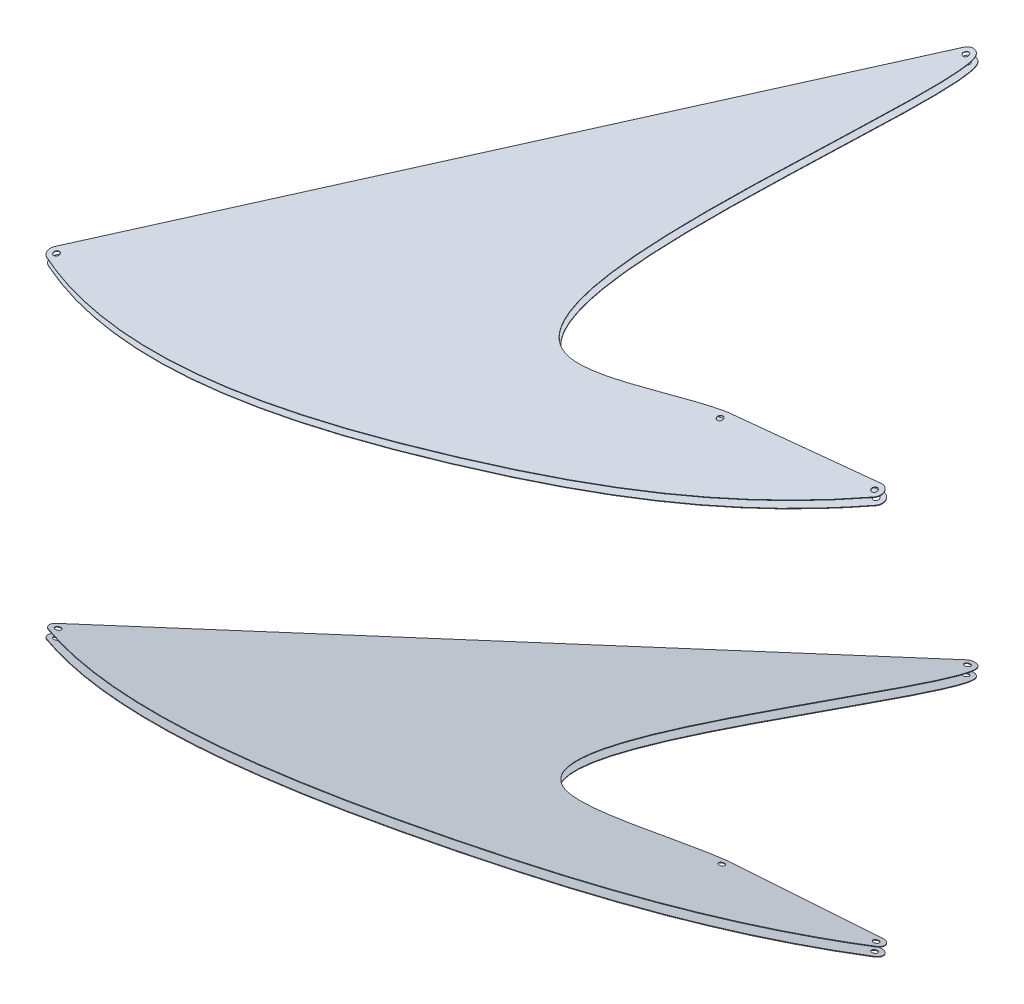
from build123d import *

# Parameters (mm, degrees)
SZKIC1_R                    = 3
SZKIC1_R_2                  = 2.999999996
DODANIE_WYCI_GNI_CIE1_DEPTH = 0.6
SZKIC2_R                    = 3
SZKIC2_R_2                  = 2.999999996
DODANIE_WYCI_GNI_CIE2_DEPTH = 0.6


with BuildPart() as part:
    # Szkic1 → Dodanie-wyciągnięcie1 (new body)
    with BuildSketch(Plane(origin=(0, -365.945689178, 71.13263619), x_dir=(1, 0, 0), z_dir=(0, -0.981627183, 0.190808995))):
        with BuildLine():
            Line((1483.1737317, 808.853368538), (1634.871598877, 794.959745005))
            ThreePointArc((1634.871598877, 794.959745005), (1642.326429132, 800.05707281), (1640.281331001, 808.853368538))
            add(Edge.make_bspline(
                [(1640.281331001, 808.853368538), (1556.499884294, 885.756004267), (1335.806413784, 985.712102893), (1065.430635851, 1046.869568532), (942.811265429, 996.129923251)],
                knots=[0, 0, 0, 0, 0.451675341, 1, 1, 1, 1], degree=3))
            ThreePointArc((942.811265429, 996.129923251), (938.177076077, 990.932618484), (939.37128434, 984.072476035))
            Line((939.37128434, 984.072476035), (1348.49049843, 414.166953328))
            ThreePointArc((1348.49049843, 414.166953328), (1355.785767616, 410.872022391), (1362.283628975, 415.546989785))
            add(Edge.make_bspline(
                [(1362.283628975, 415.546989785), (1370.507425365, 433.806229295), (1317.913749169, 619.983132718), (1275.879179559, 890.619951369), (1437.469754318, 816.5628016), (1483.1737317, 808.853368538)],
                knots=[0, 0, 0, 0, 0.358356972, 0.741720639, 1, 1, 1, 1], degree=3))
        make_face()
        with Locations((1354.98932451, 418.832278566)):
            Circle(SZKIC1_R, mode=Mode.SUBTRACT)
        with Locations((945.87011042, 988.737801274)):
            Circle(SZKIC1_R, mode=Mode.SUBTRACT)
        with Locations((1634.871598877, 802.959745005)):
            Circle(SZKIC1_R_2, mode=Mode.SUBTRACT)
        with Locations((1483.903377602, 816.820025105)):
            Circle(SZKIC1_R, mode=Mode.SUBTRACT)
    extrude(amount=DODANIE_WYCI_GNI_CIE1_DEPTH)


with BuildPart() as body_2:
    # Szkic2 → Dodanie-wyciągnięcie2 (new body)
    with BuildSketch(Plane(origin=(0, -358.092671711, 69.606164227), x_dir=(1, 0, 0), z_dir=(0, 0.981627183, -0.190808995))):
        with BuildLine():
            Line((1634.871598877, -794.959745005), (1483.1737317, -808.853368538))
            add(Edge.make_bspline(
                [(1483.1737317, -808.853368538), (1437.469754318, -816.5628016), (1275.879179559, -890.619951369), (1317.913749169, -619.983132718), (1370.507425365, -433.806229295), (1362.283628975, -415.546989785)],
                knots=[0, 0, 0, 0, 0.258279361, 0.641643028, 1, 1, 1, 1], degree=3))
            ThreePointArc((1362.283628975, -415.546989785), (1355.785767616, -410.872022391), (1348.49049843, -414.166953328))
            Line((1348.49049843, -414.166953328), (939.37128434, -984.072476035))
            ThreePointArc((939.37128434, -984.072476035), (938.177076077, -990.932618484), (942.811265429, -996.129923251))
            add(Edge.make_bspline(
                [(942.811265429, -996.129923251), (1065.430635851, -1046.869568532), (1335.806413784, -985.712102893), (1556.499884294, -885.756004267), (1640.281331001, -808.853368538)],
                knots=[0, 0, 0, 0, 0.548324659, 1, 1, 1, 1], degree=3))
            ThreePointArc((1640.281331001, -808.853368538), (1642.326429132, -800.05707281), (1634.871598877, -794.959745005))
        make_face()
        with Locations((1354.98932451, -418.832278566)):
            Circle(SZKIC2_R, mode=Mode.SUBTRACT)
        with Locations((1634.871598877, -802.959745005)):
            Circle(SZKIC2_R_2, mode=Mode.SUBTRACT)
        with Locations((1483.903377602, -816.820025105)):
            Circle(SZKIC2_R, mode=Mode.SUBTRACT)
        with Locations((945.87011042, -988.737801274)):
            Circle(SZKIC2_R, mode=Mode.SUBTRACT)
    extrude(amount=DODANIE_WYCI_GNI_CIE2_DEPTH)


with BuildPart() as body_3:
    # Lustro1: mirrored copy
    add(part.part.mirror(Plane.ZX))


with BuildPart() as body_4:
    # Lustro1 2: mirrored copy
    add(body_2.part.mirror(Plane.ZX))


solid = Compound([part.part, body_2.part, body_3.part, body_4.part])
